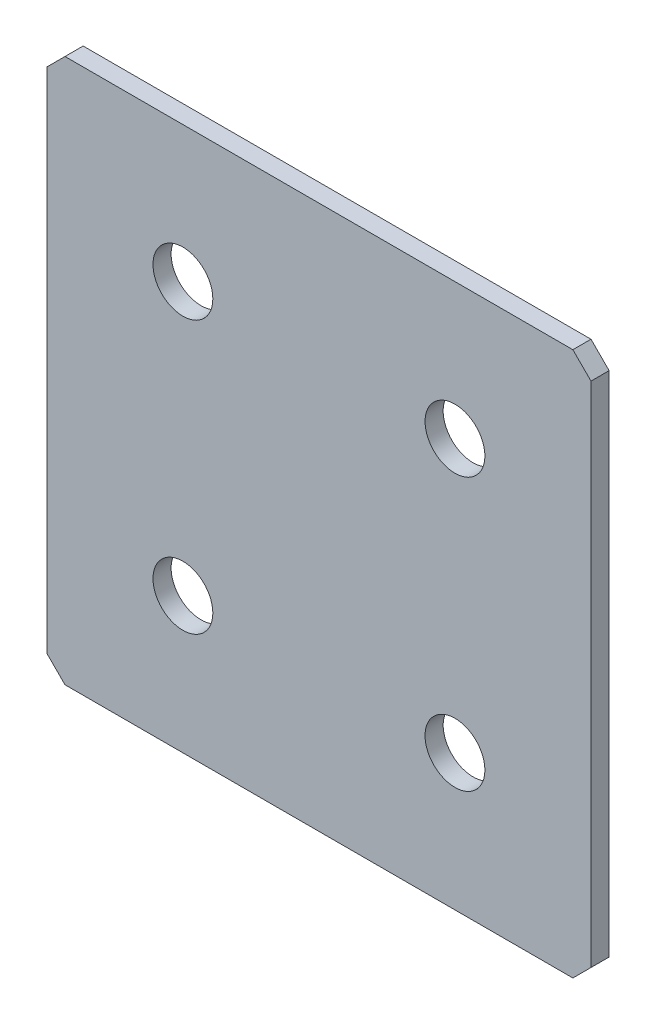
from build123d import *

# Parameters (mm, degrees)
SKETCH_1_W        = 60
SKETCH_1_H        = 60
EXTRUDE_1_DEPTH   = 2
CHAMFER_1_SIZE    = 2
HOLE_WIZARD_M61_D = 6.6


with BuildPart() as part:
    # Эскиз1 → Бобышка-Вытянуть1 (new body)
    with BuildSketch(Plane.XY):
        Rectangle(SKETCH_1_W, SKETCH_1_H)
    extrude(amount=EXTRUDE_1_DEPTH)

    # Фаска1
    chamfer_1_edges = [part.edges().sort_by_distance(p)[0] for p in [
        (30, -30, 1),
        (-30, -30, 1),
        (-30, 30, 1),
        (30, 30, 1),
    ]]
    chamfer(chamfer_1_edges, length=CHAMFER_1_SIZE)

    # Отверстие с зазором M61 (through all)
    with Locations(Plane.XY.offset(2)):
        with Locations((-15, 15), (15, 15), (-15, -15), (15, -15), (-15, 45), (15, 45), (15, -45), (-15, -45)):
            Hole(HOLE_WIZARD_M61_D / 2)


solid = part.part
